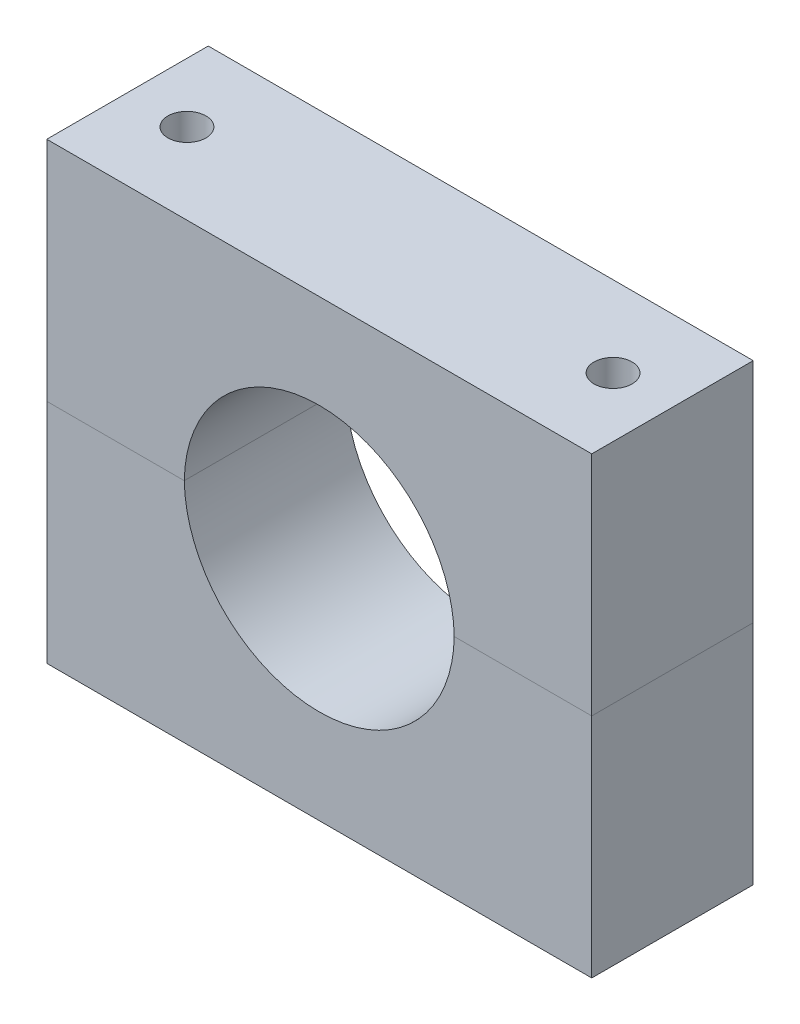
from build123d import *

# Parameters (mm, degrees)
BOSS_EXTRUDE1_DEPTH = 36
SKETCH3_W           = 36
SKETCH3_H           = 0.5
CUT_EXTRUDE1_DEPTH  = 122.5
SKETCH4_R           = 4.25
CUT_EXTRUDE2_DEPTH  = 51.6


with BuildPart() as part:
    # Sketch1 → Boss-Extrude1 (new body)
    with BuildSketch(Plane.XY):
        with BuildLine():
            Line((66.4453125, 57.087379808), (-55.0546875, 57.087379808))
            Line((-55.0546875, 57.087379808), (-55.0546875, 5.987379808))
            Line((-55.0546875, 5.987379808), (-24.4046875, 5.987379808))
            ThreePointArc((-24.4046875, 5.987379808), (5.6953125, 36.087379808), (35.7953125, 5.987379808))
            Line((35.7953125, 5.987379808), (66.4453125, 5.987379808))
            Line((66.4453125, 5.987379808), (66.4453125, 57.087379808))
        make_face()
    extrude(amount=BOSS_EXTRUDE1_DEPTH)

    # Sketch3 → Cut-Extrude1 (cut, through all)
    with BuildSketch(Plane.ZY.offset(55.0546875)):
        with Locations((18, 6.237379808)):
            Rectangle(SKETCH3_W, SKETCH3_H)
    extrude(amount=-CUT_EXTRUDE1_DEPTH, mode=Mode.SUBTRACT)

    # Sketch4 → Cut-Extrude2 (cut, through all)
    with BuildSketch(Plane(origin=(0, 57.087379808, 0), x_dir=(1, 0, 0), z_dir=(0, 1, 0))):
        with Locations((-41.8046875, -18)):
            Circle(SKETCH4_R)
        with Locations((53.1953125, -18)):
            Circle(SKETCH4_R)
    extrude(amount=-CUT_EXTRUDE2_DEPTH, mode=Mode.SUBTRACT)


with BuildPart() as body_2:
    # Mirror2: mirrored copy
    add(part.part.mirror(Plane(origin=(66.4453125, 6.487379808, 0), x_dir=(0, 0, 1), z_dir=(0, 1, 0))))


solid = Compound([part.part, body_2.part])
